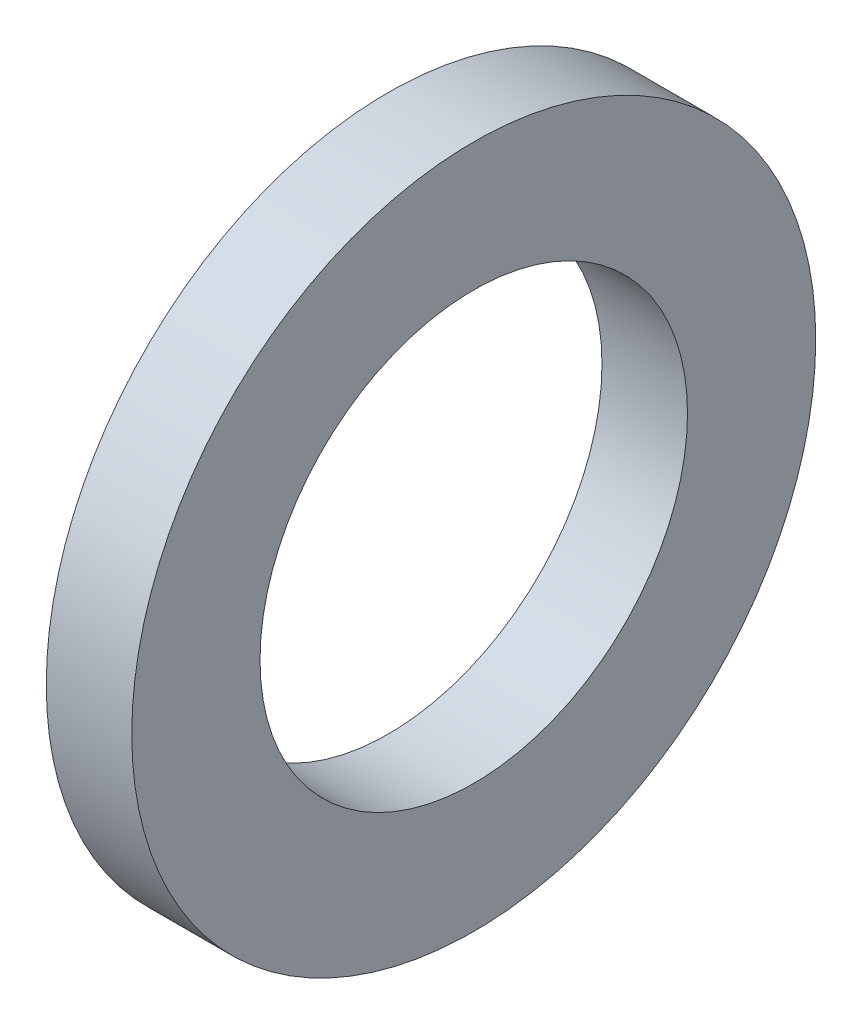
from build123d import *

# Parameters (mm, degrees)
SKETCH_2_R      = 4
SKETCH_2_R_2    = 2.5
EXTRUDE_1_DEPTH = 1


with BuildPart() as part:
    # Эскиз2 → Бобышка-Вытянуть1 (new body)
    with BuildSketch(Plane(origin=(0, 0, 0), x_dir=(0, 0, -1), z_dir=(1, 0, 0))):
        Circle(SKETCH_2_R)
        Circle(SKETCH_2_R_2, mode=Mode.SUBTRACT)
    extrude(amount=EXTRUDE_1_DEPTH)


solid = part.part
